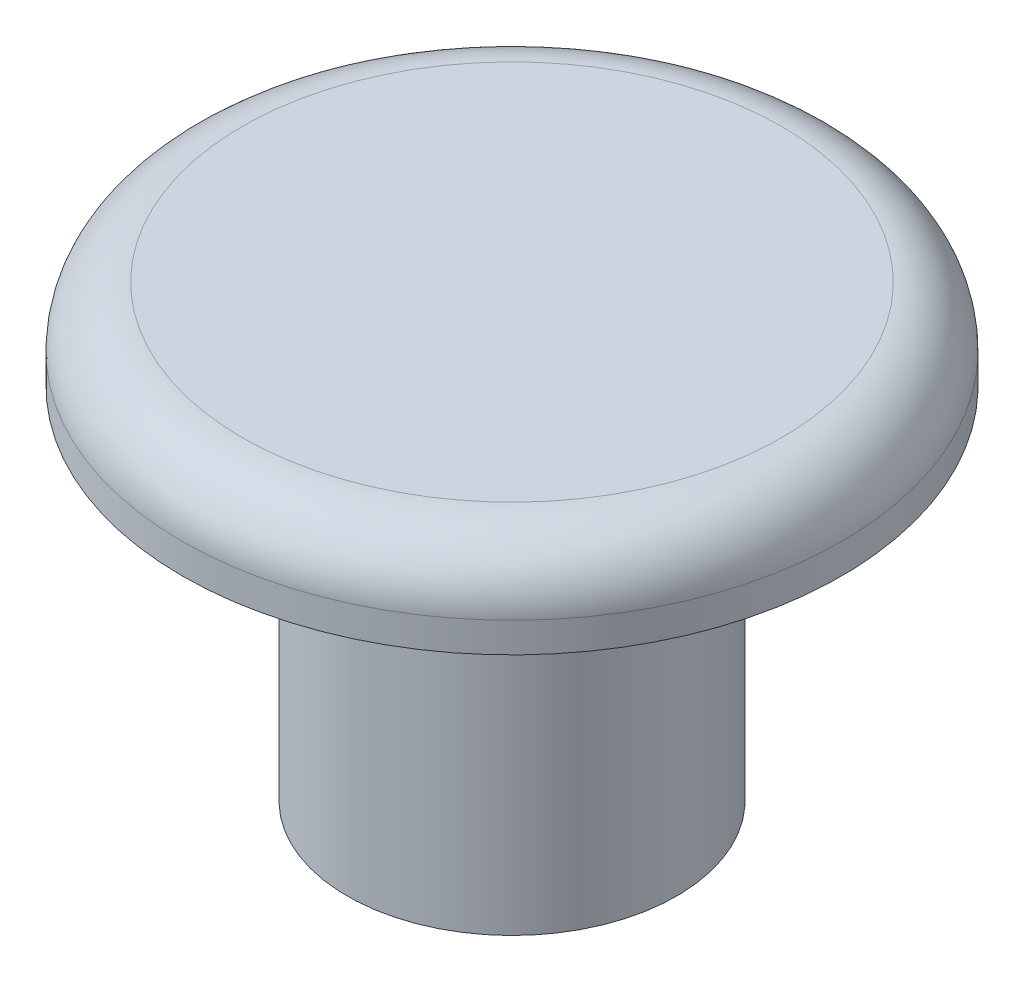
from build123d import *

# Parameters (mm, degrees)
SKETCH2_R           = 11
BOSS_EXTRUDE1_DEPTH = 3
FILLET1_R           = 2
SKETCH3_R           = 5.5
BOSS_EXTRUDE2_DEPTH = 12


with BuildPart() as part:
    # Sketch2 → Boss-Extrude1 (new body)
    with BuildSketch(Plane(origin=(0, 0, 0), x_dir=(1, 0, 0), z_dir=(0, 1, 0))):
        Circle(SKETCH2_R)
    extrude(amount=BOSS_EXTRUDE1_DEPTH)

    # Fillet1
    fillet1_edges = [part.edges().sort_by_distance(p)[0] for p in [
        (-11, 3, 0),
    ]]
    fillet(fillet1_edges, radius=FILLET1_R)

    # Sketch3 → Boss-Extrude2 (add)
    with BuildSketch(Plane.XZ):
        Circle(SKETCH3_R)
    extrude(amount=BOSS_EXTRUDE2_DEPTH)


solid = part.part
